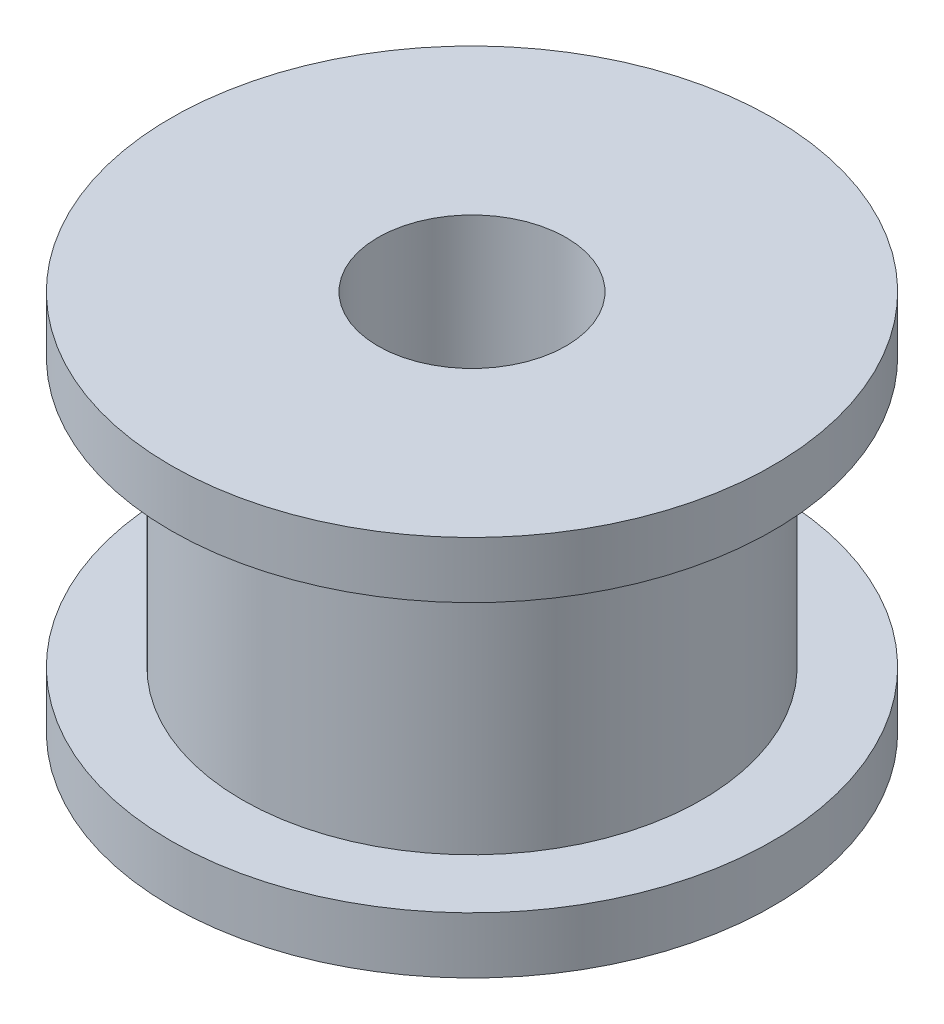
from build123d import *

# Parameters (mm, degrees)
SKETCH1_R               = 8
BOSS_EXTRUDE1_DEPTH     = 7.1
SKETCH2_R               = 6.11
BOSS_EXTRUDE2_DEPTH     = 7.14
SKETCH5_R               = 2.5
CUT_EXTRUDE2_DEPTH      = 16
SKETCH8_R               = 8
BOSS_EXTRUDE4_DEPTH     = 1.5
SKETCH9_R               = 2.5
CUT_EXTRUDE4_DEPTH      = 15.74
SKETCH10_W              = 16
SKETCH10_H              = 6
CUT_EXTRUDE5_DEPTH      = 10
CUT_EXTRUDE5_DEPTH_BACK = 10


with BuildPart() as part:
    # Sketch1 → Boss-Extrude1 (new body)
    with BuildSketch(Plane(origin=(0, 0, 0), x_dir=(1, 0, 0), z_dir=(0, 1, 0))):
        Circle(SKETCH1_R)
    extrude(amount=BOSS_EXTRUDE1_DEPTH)

    # Sketch2 → Boss-Extrude2 (add)
    with BuildSketch(Plane(origin=(0, 7.1, 0), x_dir=(1, 0, 0), z_dir=(0, 1, 0))):
        Circle(SKETCH2_R)
    extrude(amount=BOSS_EXTRUDE2_DEPTH)

    # Sketch5 → Cut-Extrude2 (cut)
    with BuildSketch(Plane.XZ):
        Circle(SKETCH5_R)
    extrude(amount=-CUT_EXTRUDE2_DEPTH, mode=Mode.SUBTRACT)

    # Sketch8 → Boss-Extrude4 (add)
    with BuildSketch(Plane(origin=(0, 14.24, 0), x_dir=(1, 0, 0), z_dir=(0, 1, 0))):
        Circle(SKETCH8_R)
    extrude(amount=BOSS_EXTRUDE4_DEPTH)

    # Sketch9 → Cut-Extrude4 (cut)
    with BuildSketch(Plane(origin=(0, 15.74, 0), x_dir=(1, 0, 0), z_dir=(0, 1, 0))):
        Circle(SKETCH9_R)
    extrude(amount=-CUT_EXTRUDE4_DEPTH, mode=Mode.SUBTRACT)

    # Sketch10 → Cut-Extrude5 (cut, two sides)
    with BuildSketch(Plane(origin=(0, 0, 0), x_dir=(0, 0, -1), z_dir=(1, 0, 0))) as cut_extrude5_sk:
        with Locations((0, 2.6)):
            Rectangle(SKETCH10_W, SKETCH10_H)
    extrude(amount=CUT_EXTRUDE5_DEPTH, mode=Mode.SUBTRACT)
    extrude(cut_extrude5_sk.sketch, amount=-CUT_EXTRUDE5_DEPTH_BACK, mode=Mode.SUBTRACT)


solid = part.part
